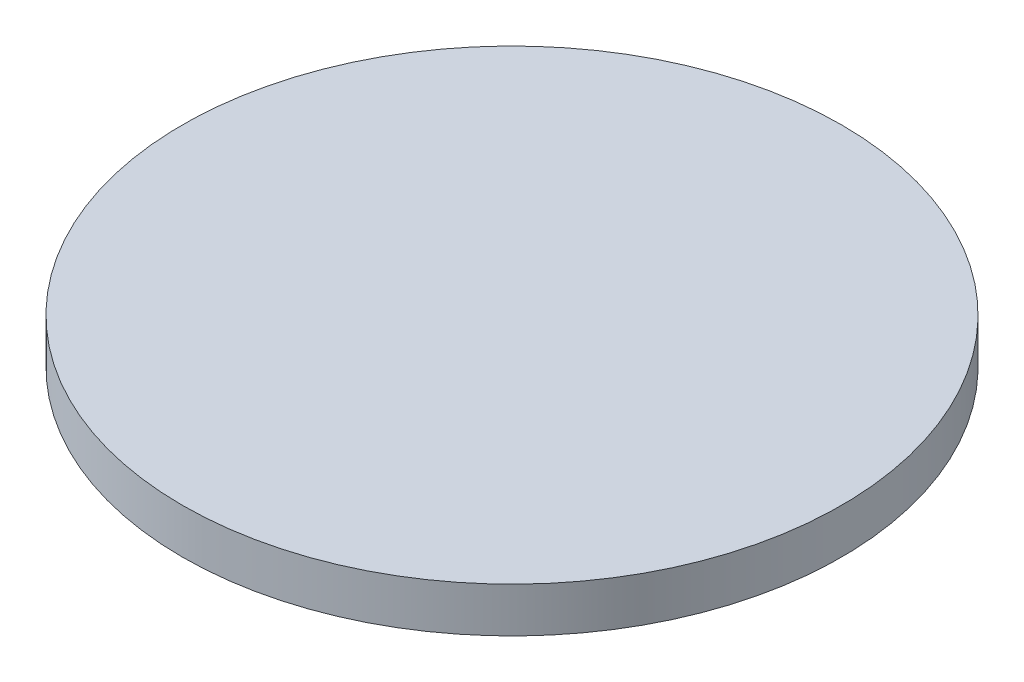
from build123d import *

# Parameters (mm, degrees)
SKETCH1_R           = 23.5
BOSS_EXTRUDE1_DEPTH = 3.2


with BuildPart() as part:
    # Sketch1 → Boss-Extrude1 (new body)
    with BuildSketch(Plane(origin=(0, 0, 0), x_dir=(1, 0, 0), z_dir=(0, 1, 0))):
        Circle(SKETCH1_R)
    extrude(amount=BOSS_EXTRUDE1_DEPTH)


solid = part.part
